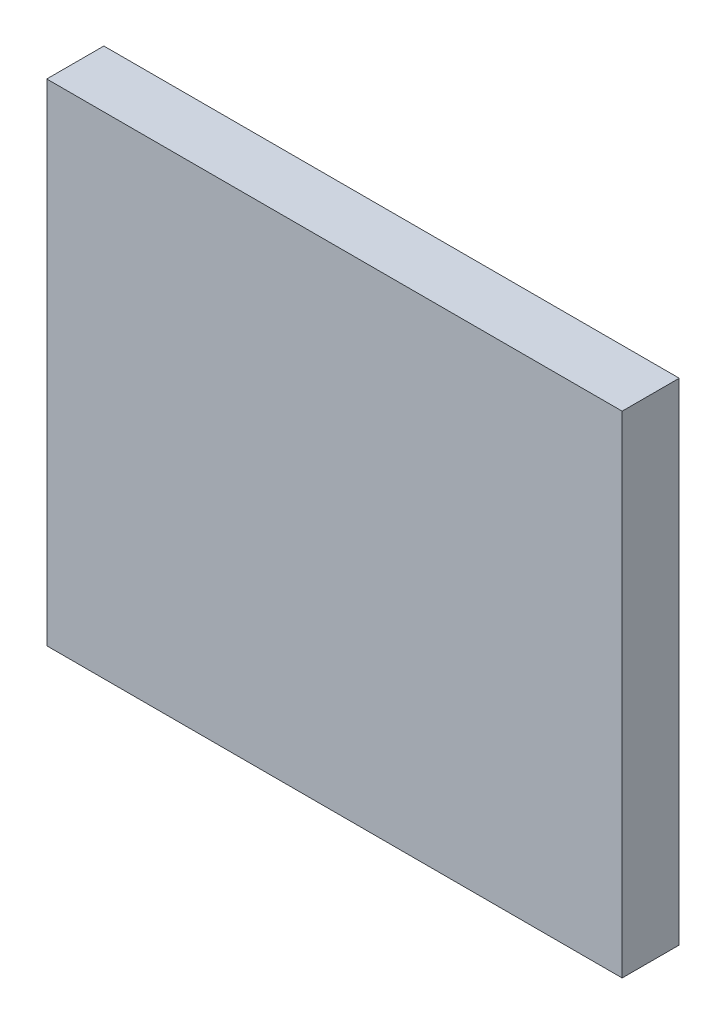
from build123d import *

# Parameters (mm, degrees)
SKETCH2_W           = 25.2
SKETCH2_H           = 21.5
BOSS_EXTRUDE1_DEPTH = 2.5


with BuildPart() as part:
    # Sketch2 → Boss-Extrude1 (new body)
    with BuildSketch(Plane.XY):
        Rectangle(SKETCH2_W, SKETCH2_H)
    extrude(amount=BOSS_EXTRUDE1_DEPTH)


solid = part.part
